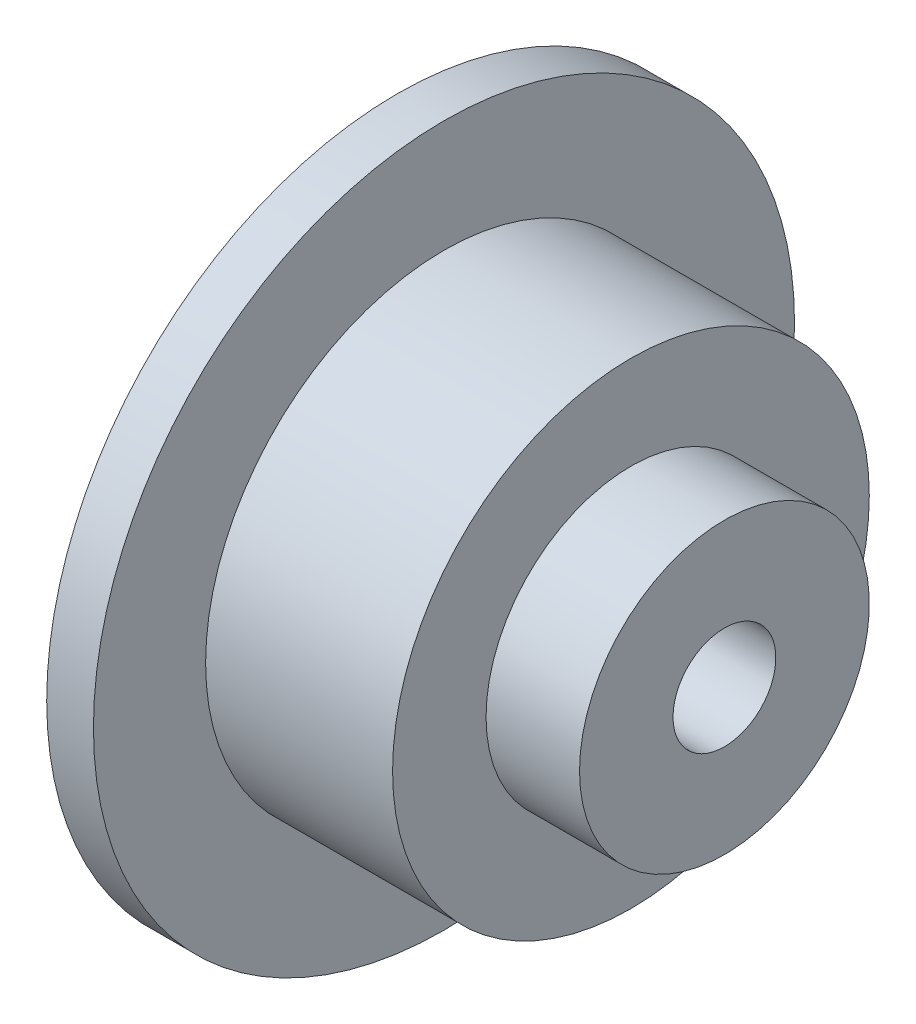
from build123d import *


with BuildPart() as part:
    # Sketch1 → Revolve1 (revolve)
    with BuildSketch(Plane(origin=(0, 0, 0), x_dir=(1, 0, 0), z_dir=(0, 1, 0))):
        Polygon((0, 2.5), (0, 7.5), (1, 7.5), (1, 5.1), (5, 5.1), (5, 3.1), (7, 3.1), (7, 1.1), (4, 1.1), (4, 2.5), align=None)
    revolve(axis=Axis((0, 0, 0), (1, 0, 0)))


solid = part.part
